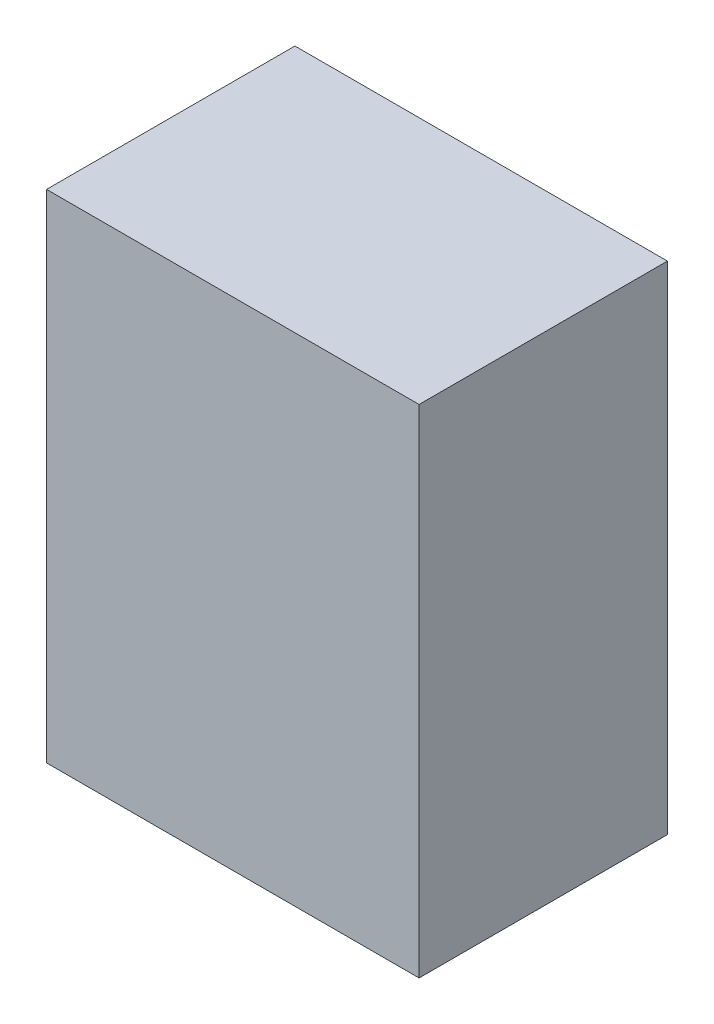
from build123d import *

# Parameters (mm, degrees)
SKETCH1_W           = 38.1
SKETCH1_H           = 25.4
BOSS_EXTRUDE1_DEPTH = 50.8


with BuildPart() as part:
    # Sketch1 → Boss-Extrude1 (new body)
    with BuildSketch(Plane(origin=(0, 0, 0), x_dir=(1, 0, 0), z_dir=(0, 1, 0))):
        with Locations((19.05, 12.7)):
            Rectangle(SKETCH1_W, SKETCH1_H)
    extrude(amount=BOSS_EXTRUDE1_DEPTH)


solid = part.part
